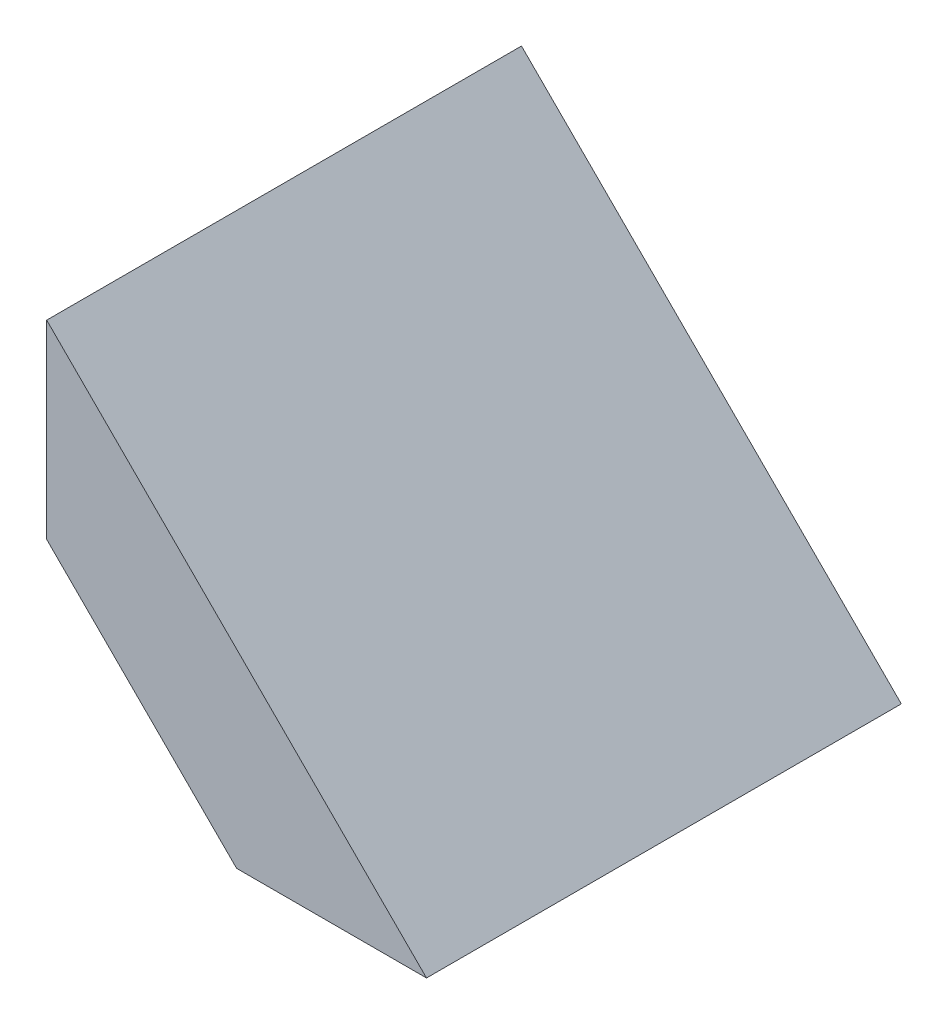
from build123d import *

# Parameters (mm, degrees)
BOSS_EXTRUDE1_DEPTH = 25


with BuildPart() as part:
    # Sketch1 → Boss-Extrude1 (new body)
    with BuildSketch(Plane.XY):
        Polygon((-20, 10), (-20, 20), (0, 0), (-10, 0), align=None)
    extrude(amount=BOSS_EXTRUDE1_DEPTH)


solid = part.part
